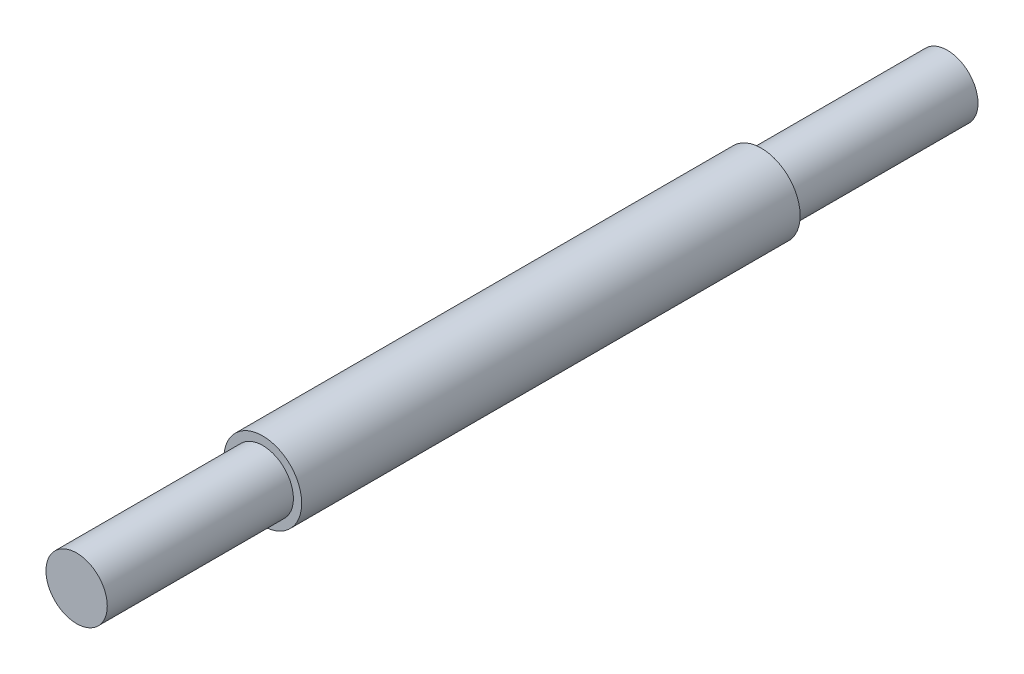
from build123d import *

# Parameters (mm, degrees)
SKETCH2_R                = 2.5
BOSS_EXTRUDE1_DEPTH      = 35.494976
BOSS_EXTRUDE1_DEPTH_BACK = 35.494976
SKETCH3_R                = 3.175
BOSS_EXTRUDE2_DEPTH      = 20.32
BOSS_EXTRUDE2_DEPTH_BACK = 20.32


with BuildPart() as part:
    # Sketch2 → Boss-Extrude1 (new body, two sides)
    with BuildSketch(Plane.XY) as boss_extrude1_sk:
        Circle(SKETCH2_R)
    extrude(amount=BOSS_EXTRUDE1_DEPTH)
    extrude(boss_extrude1_sk.sketch, amount=-BOSS_EXTRUDE1_DEPTH_BACK)

    # Sketch3 → Boss-Extrude2 (add, two sides)
    with BuildSketch(Plane.XY) as boss_extrude2_sk:
        Circle(SKETCH3_R)
    extrude(amount=BOSS_EXTRUDE2_DEPTH)
    extrude(boss_extrude2_sk.sketch, amount=-BOSS_EXTRUDE2_DEPTH_BACK)


solid = part.part
